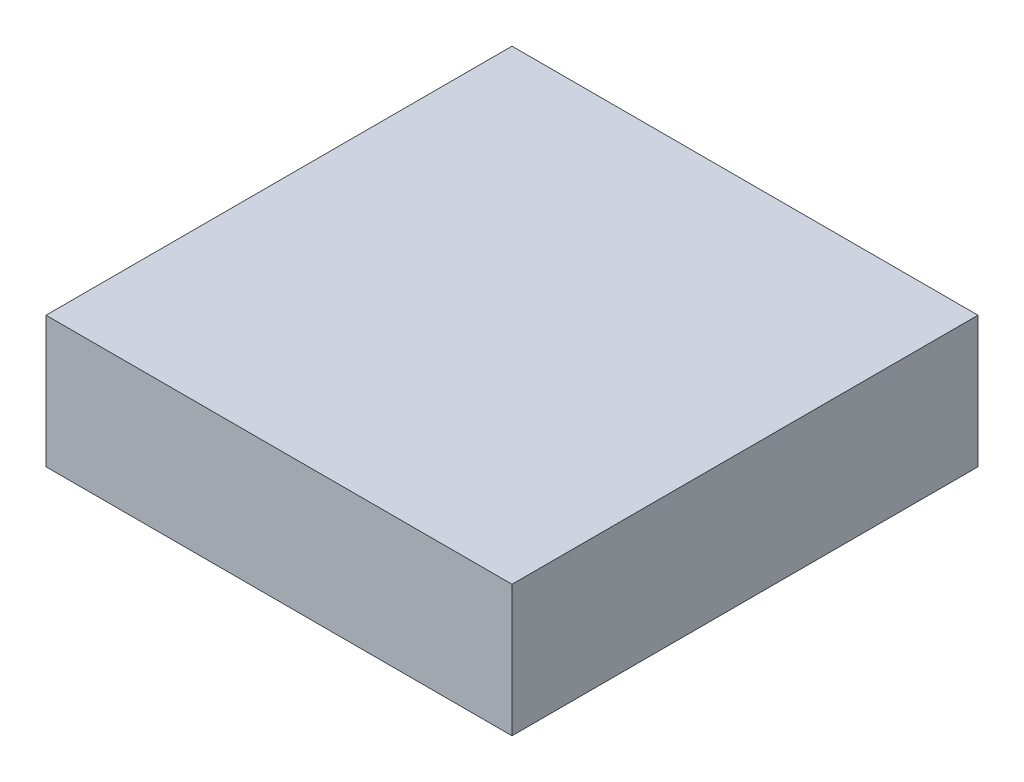
from build123d import *

# Parameters (mm, degrees)
SKIZZE1_W                       = 17.75
SKIZZE1_H                       = 17.75
AUFSATZ_LINEAR_AUSTRAGEN1_DEPTH = 5


with BuildPart() as part:
    # Skizze1 → Aufsatz-Linear austragen1 (new body)
    with BuildSketch(Plane(origin=(0, 0, 0), x_dir=(1, 0, 0), z_dir=(0, 1, 0))):
        Rectangle(SKIZZE1_W, SKIZZE1_H)
    extrude(amount=AUFSATZ_LINEAR_AUSTRAGEN1_DEPTH)


solid = part.part
